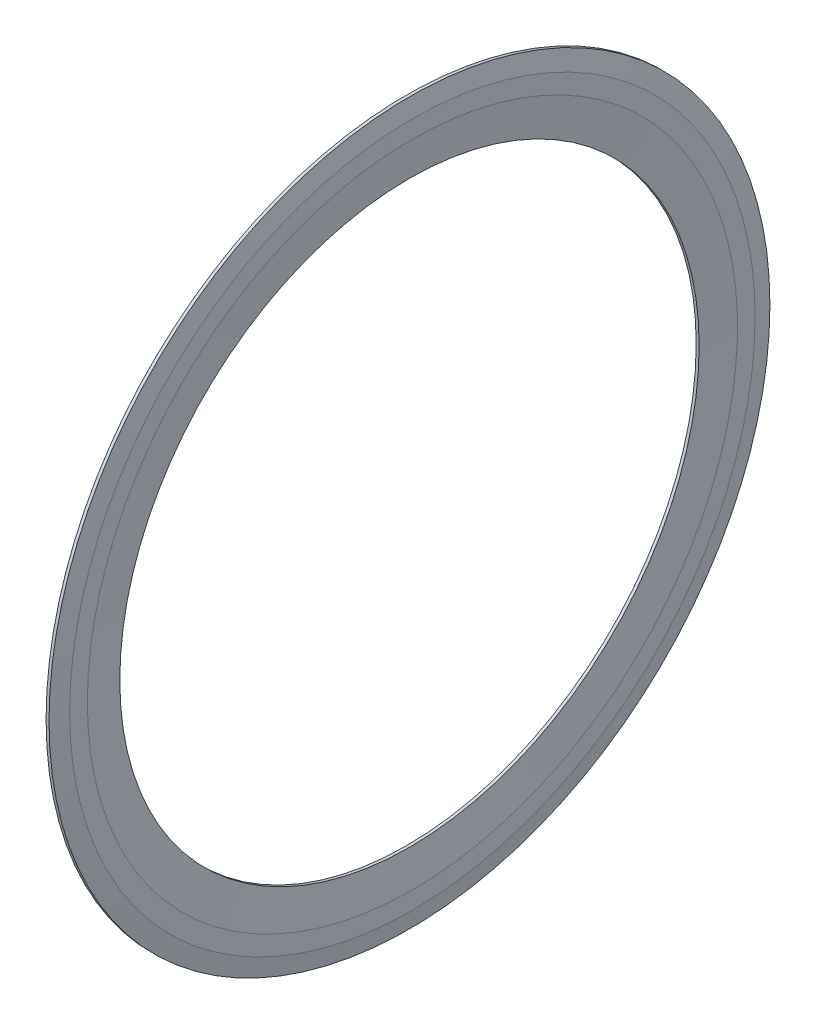
from build123d import *


with BuildPart() as part:
    # 草图1 → 旋转1 (revolve)
    with BuildSketch(Plane.XY):
        Polygon((0.27, 11.075), (0.315, 10.53125), (0.27, 9.9875), (0.27, 8.9), (0.36, 8.9), (0.45, 9.9875), (0.45, 10.53125), (0.36, 11.075), align=None)
    revolve(axis=Axis((50, 0, 0), (-1, 0, 0)))


solid = part.part
